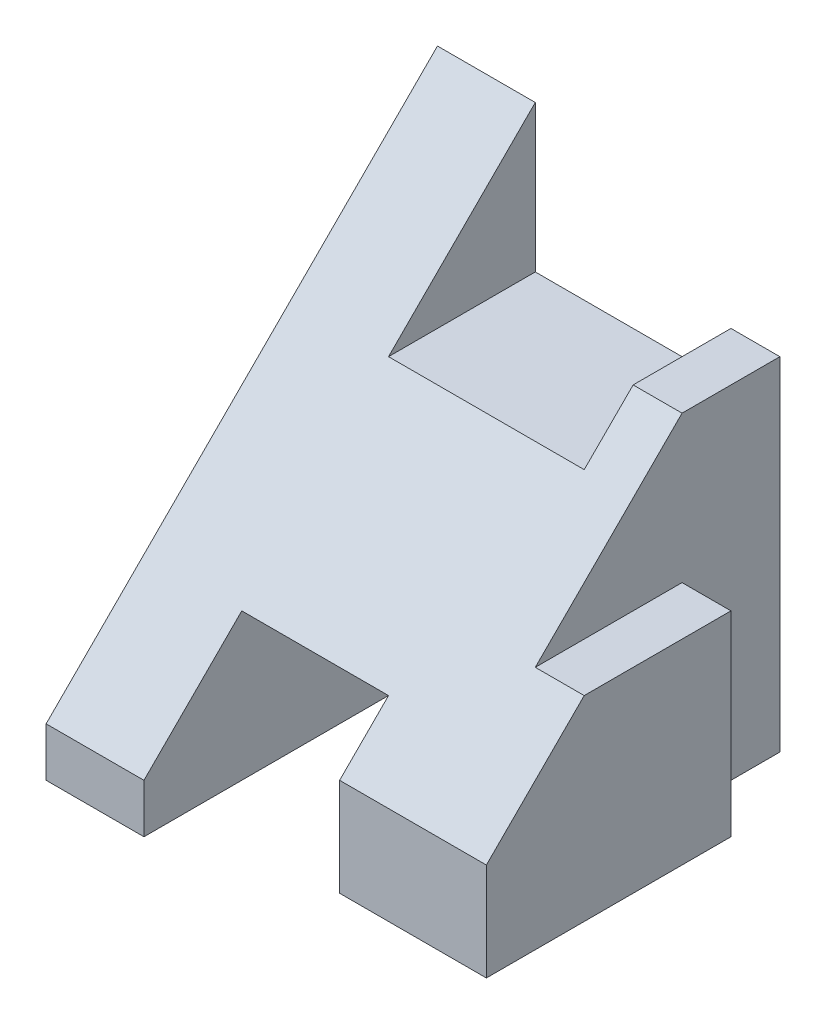
from build123d import *

# Parameters (mm, degrees)
SKETCH1_W           = 8
SKETCH1_H           = 9
BOSS_EXTRUDE1_DEPTH = 8
SKETCH2_W           = 4
SKETCH2_H           = 3
CUT_EXTRUDE1_DEPTH  = 3
SKETCH3_W           = 2
SKETCH3_H           = 2
CUT_EXTRUDE2_DEPTH  = 2
CUT_EXTRUDE3_DEPTH  = 1
CUT_EXTRUDE4_DEPTH  = 9
SKETCH6_W           = 3
SKETCH6_H           = 3
CUT_EXTRUDE5_DEPTH  = 9
SKETCH7_W           = 3
SKETCH7_H           = 1
CUT_EXTRUDE6_DEPTH  = 2


with BuildPart() as part:
    # Sketch1 → Boss-Extrude1 (new body)
    with BuildSketch(Plane.XY):
        Rectangle(SKETCH1_W, SKETCH1_H)
    extrude(amount=BOSS_EXTRUDE1_DEPTH)

    # Sketch2 → Cut-Extrude1 (cut)
    with BuildSketch(Plane(origin=(0, 4.5, 0), x_dir=(1, 0, 0), z_dir=(0, 1, 0))):
        with Locations((0, -1.5)):
            Rectangle(SKETCH2_W, SKETCH2_H)
    extrude(amount=-CUT_EXTRUDE1_DEPTH, mode=Mode.SUBTRACT)

    # Sketch3 → Cut-Extrude2 (cut)
    with BuildSketch(Plane(origin=(0, 4.5, 0), x_dir=(1, 0, 0), z_dir=(0, 1, 0))):
        with Locations((3, -1)):
            Rectangle(SKETCH3_W, SKETCH3_H)
    extrude(amount=-CUT_EXTRUDE2_DEPTH, mode=Mode.SUBTRACT)

    # Sketch4 → Cut-Extrude3 (cut)
    with BuildSketch(Plane(origin=(4, 0, 0), x_dir=(0, 0, -1), z_dir=(1, 0, 0))):
        Polygon((0, -4.5), (0, 2.5), (-2, 2.5), (-5, -0.5), (-2, -0.5), (-2, -4.5), align=None)
    extrude(amount=-CUT_EXTRUDE3_DEPTH, mode=Mode.SUBTRACT)

    # Sketch5 → Cut-Extrude4 (cut, through all)
    with BuildSketch(Plane(origin=(4, 0, 0), x_dir=(0, 0, -1), z_dir=(1, 0, 0))):
        Polygon((0, 4.5), (-8, -3.5), (-8, 4.5), align=None)
    extrude(amount=-CUT_EXTRUDE4_DEPTH, mode=Mode.SUBTRACT)

    # Sketch6 → Cut-Extrude5 (cut, through all)
    with BuildSketch(Plane(origin=(0, 0, 0), x_dir=(-1, 0, 0), z_dir=(0, 0, -1))):
        with Locations((0.5, -3)):
            Rectangle(SKETCH6_W, SKETCH6_H)
    extrude(amount=-CUT_EXTRUDE5_DEPTH, mode=Mode.SUBTRACT)

    # Sketch7 → Cut-Extrude6 (cut)
    with BuildSketch(Plane.XZ.offset(4.5)):
        with Locations((2.5, 7.5)):
            Rectangle(SKETCH7_W, SKETCH7_H)
    extrude(amount=-CUT_EXTRUDE6_DEPTH, mode=Mode.SUBTRACT)


solid = part.part
